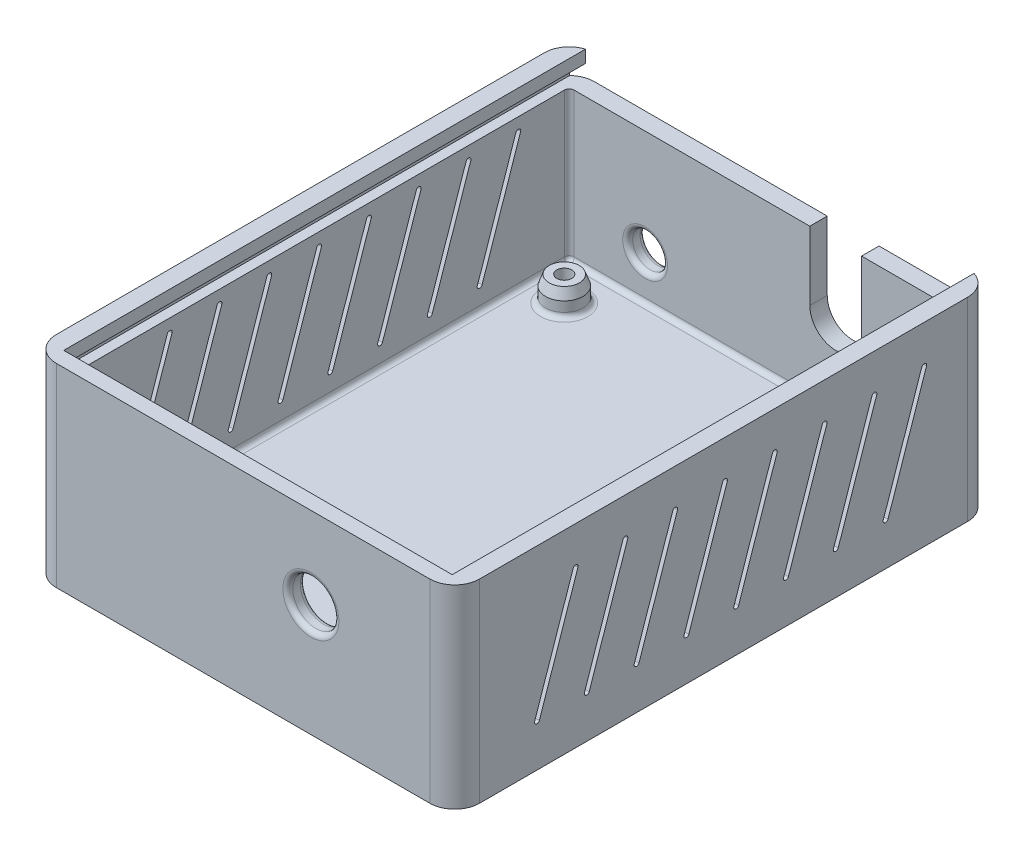
from build123d import *

# Parameters (mm, degrees)
SKETCH1_W             = 85
SKETCH1_H             = 108
BOSS_EXTRUDE1_DEPTH   = 4
SKETCH2_W             = 85
SKETCH2_H             = 108
SKETCH2_W_2           = 78
SKETCH2_H_2           = 101
BOSS_EXTRUDE2_DEPTH   = 35
SKETCH3_R             = 3.75
BOSS_EXTRUDE3_DEPTH   = 5
CHAMFER1_SIZE         = 2
CHAMFER1_SIZE2        = 0.727940469
CHAMFER1_PART_2_SIZE  = 2
CHAMFER1_PART_2_SIZE2 = 0.727940469
CHAMFER1_PART_3_SIZE  = 2
CHAMFER1_PART_3_SIZE2 = 0.727940469
CHAMFER1_PART_4_SIZE  = 2
CHAMFER1_PART_4_SIZE2 = 0.727940469
FILLET1_R             = 5
CUT_EXTRUDE1_DEPTH    = 106.5
SKETCH5_W             = 78
SKETCH5_H             = 2.5
BOSS_EXTRUDE4_DEPTH   = 1.5
CUT_EXTRUDE2_REACH    = 110
SKETCH7_R             = 1.5
CUT_EXTRUDE3_DEPTH    = 4
CUT_EXTRUDE4_DEPTH    = 85
FILLET2_R             = 1
CUT_EXTRUDE5_REACH    = 110
SKETCH9_R             = 4.625
FILLET3_R             = 1
CUT_EXTRUDE6_REACH    = 110
SKETCH10_R            = 3.5
FILLET4_R             = 1


with BuildPart() as part:
    # Sketch1 → Boss-Extrude1 (new body)
    with BuildSketch(Plane(origin=(0, 0, 0), x_dir=(1, 0, 0), z_dir=(0, 1, 0))):
        with Locations((-13.627819549, -1.769423559)):
            Rectangle(SKETCH1_W, SKETCH1_H)
    extrude(amount=BOSS_EXTRUDE1_DEPTH)

    # Sketch2 → Boss-Extrude2 (add)
    with BuildSketch(Plane(origin=(0, 4, 0), x_dir=(1, 0, 0), z_dir=(0, 1, 0))):
        with Locations((-13.627819549, -1.769423559)):
            Rectangle(SKETCH2_W, SKETCH2_H)
        with Locations((-13.627819549, -1.769423559)):
            Rectangle(SKETCH2_W_2, SKETCH2_H_2, mode=Mode.SUBTRACT)
    extrude(amount=BOSS_EXTRUDE2_DEPTH)

    # Sketch3 → Boss-Extrude3 (add)
    with BuildSketch(Plane(origin=(0, 4, 0), x_dir=(1, 0, 0), z_dir=(0, 1, 0))):
        with Locations(Location((-45.627819549, 40.730576441, 0), (0, 0, 270))):  # turned: the seam where the file's is
            Circle(SKETCH3_R)
        with Locations(Location((18.372180451, 40.730576441, 0), (0, 0, 270))):  # turned: the seam where the file's is
            Circle(SKETCH3_R)
        with Locations(Location((18.372180451, -45.269423559, 0), (0, 0, 270))):  # turned: the seam where the file's is
            Circle(SKETCH3_R)
        with Locations(Location((-45.627819549, -45.269423559, 0), (0, 0, 270))):  # turned: the seam where the file's is
            Circle(SKETCH3_R)
    extrude(amount=BOSS_EXTRUDE3_DEPTH)

    # Chamfer1
    chamfer1_edges = [part.edges().sort_by_distance(p)[0] for p in [
        (-45.627819549, 9, -44.480576441),
    ]]
    chamfer1_side = [part.faces().sort_by_distance(p)[0] for p in [
        (-45.627819549, 6.5, -44.480576441),
    ]]
    chamfer(chamfer1_edges, length=CHAMFER1_SIZE, length2=CHAMFER1_SIZE2, reference=chamfer1_side[0])

    # Chamfer1 part 2
    chamfer1_part_2_edges = [part.edges().sort_by_distance(p)[0] for p in [
        (18.372180451, 9, -44.480576441),
    ]]
    chamfer1_part_2_side = [part.faces().sort_by_distance(p)[0] for p in [
        (18.372180451, 6.5, -44.480576441),
    ]]
    chamfer(chamfer1_part_2_edges, length=CHAMFER1_PART_2_SIZE, length2=CHAMFER1_PART_2_SIZE2, reference=chamfer1_part_2_side[0])

    # Chamfer1 part 3
    chamfer1_part_3_edges = [part.edges().sort_by_distance(p)[0] for p in [
        (18.372180451, 9, 41.519423559),
    ]]
    chamfer1_part_3_side = [part.faces().sort_by_distance(p)[0] for p in [
        (18.372180451, 6.5, 41.519423559),
    ]]
    chamfer(chamfer1_part_3_edges, length=CHAMFER1_PART_3_SIZE, length2=CHAMFER1_PART_3_SIZE2, reference=chamfer1_part_3_side[0])

    # Chamfer1 part 4
    chamfer1_part_4_edges = [part.edges().sort_by_distance(p)[0] for p in [
        (-45.627819549, 9, 41.519423559),
    ]]
    chamfer1_part_4_side = [part.faces().sort_by_distance(p)[0] for p in [
        (-45.627819549, 6.5, 41.519423559),
    ]]
    chamfer(chamfer1_part_4_edges, length=CHAMFER1_PART_4_SIZE, length2=CHAMFER1_PART_4_SIZE2, reference=chamfer1_part_4_side[0])

    # Fillet1
    fillet1_edges = [part.edges().sort_by_distance(p)[0] for p in [
        (-56.127819549, 19.5, -52.230576441),
        (28.872180451, 19.5, -52.230576441),
        (28.872180451, 19.5, 55.769423559),
        (-56.127819549, 19.5, 55.769423559),
    ]]
    fillet(fillet1_edges, radius=FILLET1_R)

    # Sketch4 → Cut-Extrude1 (cut)
    with BuildSketch(Plane(origin=(0, 0, -52.230576441), x_dir=(-1, 0, 0), z_dir=(0, 0, -1))):
        Polygon((-27.372180451, 36.5), (-25.372180451, 36.5), (-25.372180451, 39), (52.627819549, 39), (52.627819549, 36.5), (54.627819549, 36.5), (54.627819549, 34), (-27.372180451, 34), align=None)
    extrude(amount=-CUT_EXTRUDE1_DEPTH, mode=Mode.SUBTRACT)

    # Sketch5 → Boss-Extrude4 (add)
    with BuildSketch(Plane(origin=(0, 0, 54.269423559), x_dir=(-1, 0, 0), z_dir=(0, 0, -1))):
        with Locations((13.627819549, 37.75)):
            Rectangle(SKETCH5_W, SKETCH5_H)
    extrude(amount=BOSS_EXTRUDE4_DEPTH)

    # Sketch6 → Cut-Extrude2 (cut, up to next)
    with BuildSketch(Plane(origin=(0, 0, -52.230576441), x_dir=(-1, 0, 0), z_dir=(0, 0, -1)), mode=Mode.PRIVATE) as cut_extrude2_sk1:
        with BuildLine():
            Line((-6.072180451, 39), (4.327819549, 39))
            Line((4.327819549, 39), (4.327819549, 20.2))
            ThreePointArc((4.327819549, 20.2), (-0.872180451, 15), (-6.072180451, 20.2))
            Line((-6.072180451, 20.2), (-6.072180451, 39))
        make_face()
    cut_extrude2_tool1 = extrude(cut_extrude2_sk1.sketch, amount=-CUT_EXTRUDE2_REACH, mode=Mode.PRIVATE) & part.part
    add(cut_extrude2_tool1.solids().sort_by_distance((0.87218, 27.528533, -52.230576))[0], mode=Mode.SUBTRACT)

    # Sketch7 → Cut-Extrude3 (cut)
    with BuildSketch(Plane(origin=(0, 9, 0), x_dir=(1, 0, 0), z_dir=(0, 1, 0))):
        with Locations(Location((18.372180451, -45.269423559, 0), (0, 0, 270))):  # turned: the seam where the file's is
            Circle(SKETCH7_R)
        with Locations(Location((-45.627819549, -45.269423559, 0), (0, 0, 270))):  # turned: the seam where the file's is
            Circle(SKETCH7_R)
        with Locations(Location((18.372180451, 40.730576441, 0), (0, 0, 270))):  # turned: the seam where the file's is
            Circle(SKETCH7_R)
        with Locations(Location((-45.627819549, 40.730576441, 0), (0, 0, 270))):  # turned: the seam where the file's is
            Circle(SKETCH7_R)
    extrude(amount=-CUT_EXTRUDE3_DEPTH, mode=Mode.SUBTRACT)

    # Sketch8 → Cut-Extrude4 (cut)
    with BuildSketch(Plane.ZY.offset(56.127819549)):
        with BuildLine():
            Line((-38.024981889, 31.477071371), (-30.277052664, 8.704726707))
            ThreePointArc((-30.277052664, 8.704726707), (-30.589354536, 8.070323411), (-31.223757831, 8.382625283))
            Line((-31.223757831, 8.382625283), (-38.971687056, 31.154969948))
            ThreePointArc((-38.971687056, 31.154969948), (-38.659385185, 31.789373243), (-38.024981889, 31.477071371))
        make_face()
        with BuildLine():
            Line((-28.024981889, 31.477071371), (-20.277052664, 8.704726707))
            ThreePointArc((-20.277052664, 8.704726707), (-20.589354536, 8.070323411), (-21.223757831, 8.382625283))
            Line((-21.223757831, 8.382625283), (-28.971687056, 31.154969948))
            ThreePointArc((-28.971687056, 31.154969948), (-28.659385185, 31.789373243), (-28.024981889, 31.477071371))
        make_face()
        with BuildLine():
            Line((-18.024981889, 31.477071371), (-10.277052664, 8.704726707))
            ThreePointArc((-10.277052664, 8.704726707), (-10.589354536, 8.070323411), (-11.223757831, 8.382625283))
            Line((-11.223757831, 8.382625283), (-18.971687056, 31.154969948))
            ThreePointArc((-18.971687056, 31.154969948), (-18.659385185, 31.789373243), (-18.024981889, 31.477071371))
        make_face()
        with BuildLine():
            Line((-8.024981889, 31.477071371), (-0.277052664, 8.704726707))
            ThreePointArc((-0.277052664, 8.704726707), (-0.589354536, 8.070323411), (-1.223757831, 8.382625283))
            Line((-1.223757831, 8.382625283), (-8.971687056, 31.154969948))
            ThreePointArc((-8.971687056, 31.154969948), (-8.659385185, 31.789373243), (-8.024981889, 31.477071371))
        make_face()
        with BuildLine():
            Line((1.975018111, 31.477071371), (9.722947336, 8.704726707))
            ThreePointArc((9.722947336, 8.704726707), (9.410645464, 8.070323411), (8.776242169, 8.382625283))
            Line((8.776242169, 8.382625283), (1.028312944, 31.154969948))
            ThreePointArc((1.028312944, 31.154969948), (1.340614815, 31.789373243), (1.975018111, 31.477071371))
        make_face()
        with BuildLine():
            Line((11.975018111, 31.477071371), (19.722947336, 8.704726707))
            ThreePointArc((19.722947336, 8.704726707), (19.410645464, 8.070323411), (18.776242169, 8.382625283))
            Line((18.776242169, 8.382625283), (11.028312944, 31.154969948))
            ThreePointArc((11.028312944, 31.154969948), (11.340614815, 31.789373243), (11.975018111, 31.477071371))
        make_face()
        with BuildLine():
            Line((21.975018111, 31.477071371), (29.722947336, 8.704726707))
            ThreePointArc((29.722947336, 8.704726707), (29.410645464, 8.070323411), (28.776242169, 8.382625283))
            Line((28.776242169, 8.382625283), (21.028312944, 31.154969948))
            ThreePointArc((21.028312944, 31.154969948), (21.340614815, 31.789373243), (21.975018111, 31.477071371))
        make_face()
        with BuildLine():
            Line((31.975018111, 31.477071371), (39.722947336, 8.704726707))
            ThreePointArc((39.722947336, 8.704726707), (39.410645464, 8.070323411), (38.776242169, 8.382625283))
            Line((38.776242169, 8.382625283), (31.028312944, 31.154969948))
            ThreePointArc((31.028312944, 31.154969948), (31.340614815, 31.789373243), (31.975018111, 31.477071371))
        make_face()
    extrude(amount=-CUT_EXTRUDE4_DEPTH, mode=Mode.SUBTRACT)

    # Fillet2
    fillet2_edges = [part.edges().sort_by_distance(p)[0] for p in [
        (-13.627819549, 4, -48.730576441),
        (-52.627819549, 4, 1.769423559),
        (-13.627819549, 4, 52.269423559),
        (25.372180451, 4, 1.769423559),
        (-45.627819549, 4, -44.480576441),
        (18.372180451, 4, -44.480576441),
        (18.372180451, 4, 41.519423559),
        (-45.627819549, 4, 41.519423559),
        (25.372180451, 19, 52.269423559),
        (25.372180451, 19, -48.730576441),
        (-52.627819549, 19, 52.269423559),
        (-52.627819549, 19, -48.730576441),
    ]]
    fillet(fillet2_edges, radius=FILLET2_R)

    # Sketch9 → Cut-Extrude5 (cut, up to next)
    with BuildSketch(Plane.XY.offset(55.769423559), mode=Mode.PRIVATE) as cut_extrude5_sk1:
        with Locations((0, 22.580722236)):
            Circle(SKETCH9_R)
    cut_extrude5_tool1 = extrude(cut_extrude5_sk1.sketch, amount=-CUT_EXTRUDE5_REACH, mode=Mode.PRIVATE) & part.part
    add(cut_extrude5_tool1.solids().sort_by_distance((0, 22.580722, 55.769424))[0], mode=Mode.SUBTRACT)

    # Fillet3
    fillet3_edges = [part.edges().sort_by_distance(p)[0] for p in [
        (-4.625, 22.580722236, 52.269423559),
        (-4.625, 22.580722236, 55.769423559),
    ]]
    fillet(fillet3_edges, radius=FILLET3_R)

    # Sketch10 → Cut-Extrude6 (cut, up to next)
    with BuildSketch(Plane(origin=(0, 0, -52.230576441), x_dir=(-1, 0, 0), z_dir=(0, 0, -1)), mode=Mode.PRIVATE) as cut_extrude6_sk1:
        with Locations((37.396713349, 12.877554574)):
            Circle(SKETCH10_R)
    cut_extrude6_tool1 = extrude(cut_extrude6_sk1.sketch, amount=-CUT_EXTRUDE6_REACH, mode=Mode.PRIVATE) & part.part
    add(cut_extrude6_tool1.solids().sort_by_distance((-37.396713, 12.877555, -52.230576))[0], mode=Mode.SUBTRACT)

    # Fillet4
    fillet4_edges = [part.edges().sort_by_distance(p)[0] for p in [
        (-33.896713349, 12.877554574, -48.730576441),
        (-33.896713349, 12.877554574, -52.230576441),
    ]]
    fillet(fillet4_edges, radius=FILLET4_R)


solid = part.part
